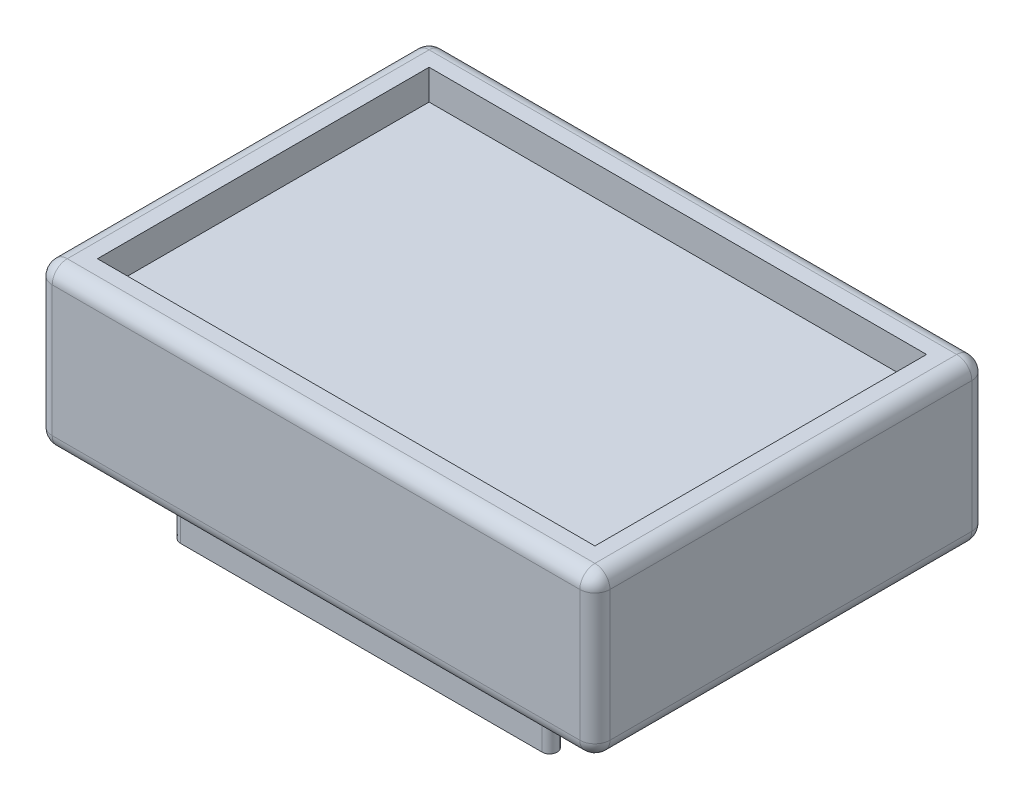
from build123d import *

# Parameters (mm, degrees)
SKETCH1_W           = 93.98
SKETCH1_H           = 66.04
SKETCH1_W_2         = 83.82
SKETCH1_H_2         = 55.88
BOSS_EXTRUDE1_DEPTH = 27.08
SKETCH3_W           = 83.82
SKETCH3_H           = 55.88
BOSS_EXTRUDE2_DEPTH = 22
BOSS_EXTRUDE3_DEPTH = 10
FILLET1_R           = 2.54


with BuildPart() as part:
    # Sketch1 → Boss-Extrude1 (new body)
    with BuildSketch(Plane(origin=(0, 0, 0), x_dir=(1, 0, 0), z_dir=(0, 1, 0))):
        Rectangle(SKETCH1_W, SKETCH1_H)
        Rectangle(SKETCH1_W_2, SKETCH1_H_2, mode=Mode.SUBTRACT)
    extrude(amount=BOSS_EXTRUDE1_DEPTH)

    # Sketch3 → Boss-Extrude2 (add)
    with BuildSketch(Plane(origin=(0, 0, 0), x_dir=(1, 0, 0), z_dir=(0, 1, 0))):
        Rectangle(SKETCH3_W, SKETCH3_H)
    extrude(amount=BOSS_EXTRUDE2_DEPTH)

    # Sketch4 → Boss-Extrude3 (add)
    with BuildSketch(Plane.XZ):
        with BuildLine():
            Line((-30.48, 25.4), (30.48, 25.4))
            ThreePointArc((30.48, 25.4), (31.75, 24.13), (30.48, 22.86))
            Line((30.48, 22.86), (-30.48, 22.86))
            ThreePointArc((-30.48, 22.86), (-31.75, 24.13), (-30.48, 25.4))
        make_face()
    extrude(amount=BOSS_EXTRUDE3_DEPTH)

    # Fillet1
    fillet1_edges = [part.edges().sort_by_distance(p)[0] for p in [
        (46.99, 27.08, 0),
        (0, 27.08, -33.02),
        (-46.99, 27.08, 0),
        (0, 0, -33.02),
        (46.99, 0, 0),
        (0, 0, 33.02),
        (-46.99, 0, 0),
        (-46.99, 13.54, -33.02),
        (46.99, 13.54, -33.02),
        (46.99, 13.54, 33.02),
        (-46.99, 13.54, 33.02),
        (0, 27.08, 33.02),
    ]]
    fillet(fillet1_edges, radius=FILLET1_R)


solid = part.part
